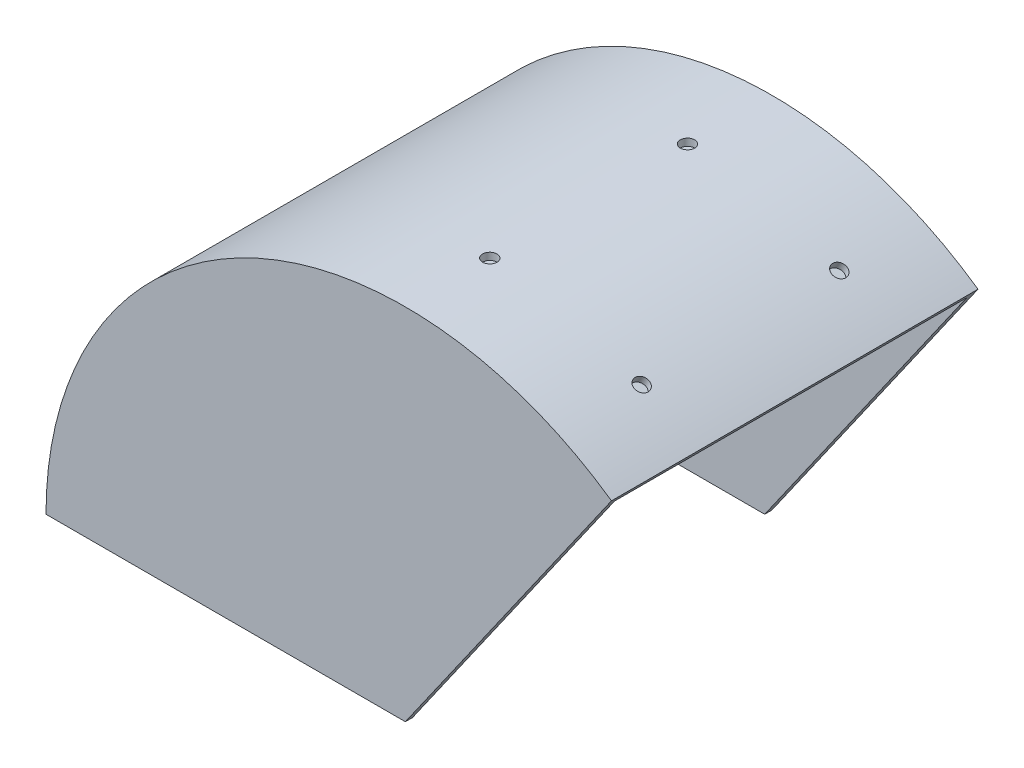
from build123d import *

# Parameters (mm, degrees)
BOSS_EXTRUDE1_DEPTH = 129.54
SKETCH2_R           = 2.54
CUT_EXTRUDE1_DEPTH  = 2.54
SKETCH4_R           = 2.54
CUT_EXTRUDE2_DEPTH  = 2.54
CUT_EXTRUDE3_DEPTH  = 130.5400001
SHELL1_T            = -2.54


with BuildPart() as part:
    # Sketch1 → Boss-Extrude1 (new body)
    with BuildSketch(Plane.XY):
        with BuildLine():
            Line((127, 0), (0, 0))
            Line((0, 0), (-127, 0))
            ThreePointArc((-127, 0), (0, 127), (127, 0))
        make_face()
    extrude(amount=BOSS_EXTRUDE1_DEPTH)

    # Sketch2 → Cut-Extrude1 (cut)
    with BuildSketch(Plane(origin=(0, 127, 129.54), x_dir=(1, 0, 0), z_dir=(0, 1, 0))):
        with Locations((0, 29.845)):
            Circle(SKETCH2_R)
        with Locations((0, 99.695)):
            Circle(SKETCH2_R)
    extrude(amount=-CUT_EXTRUDE1_DEPTH, mode=Mode.SUBTRACT)

    # Sketch4 → Cut-Extrude2 (cut)
    with BuildSketch(Plane(origin=(53.676536994, 115.099215359, 129.54), x_dir=(0.906293034, -0.422649898, 0), z_dir=(0.422649898, 0.906293034, 0))):
        with Locations((0, 29.845)):
            Circle(SKETCH4_R)
        with Locations((0, 99.695)):
            Circle(SKETCH4_R)
    extrude(amount=-CUT_EXTRUDE2_DEPTH, mode=Mode.SUBTRACT)

    # Sketch5 → Cut-Extrude3 (cut, through all)
    with BuildSketch(Plane.XY.offset(129.54)):
        with BuildLine():
            Line((72.844207417, 104.032309625), (0, 0))
            Line((0, 0), (127, 0))
            ThreePointArc((127, 0), (112.650375814, 58.642073881), (72.844207417, 104.032309625))
        make_face()
    extrude(amount=-CUT_EXTRUDE3_DEPTH, mode=Mode.SUBTRACT)

    # Shell1
    shell1_openings = [part.faces().sort_by_distance(p)[0] for p in [
        (-63.5, 0, 64.77),
        (36.422103708, 52.016154812, 64.77),
    ]]
    offset(amount=SHELL1_T, openings=shell1_openings, kind=Kind.INTERSECTION)


solid = part.part
